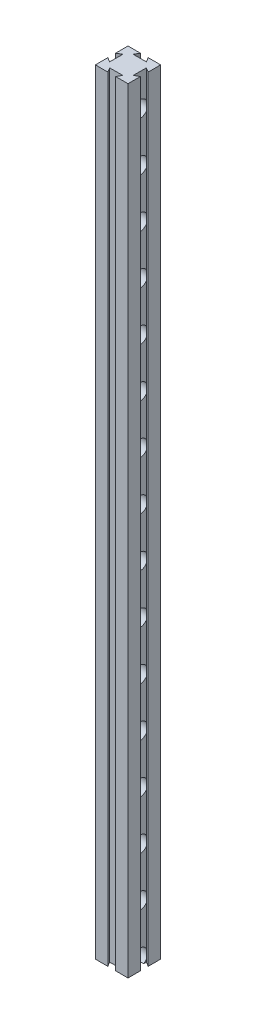
from build123d import *

# Parameters (mm, degrees)
BOSS_EXTRUDE1_DEPTH     = 1186
SKETCH3_R               = 12.5
CUT_EXTRUDE1_DEPTH      = 18
CUT_EXTRUDE1_DEPTH_BACK = 18


with BuildPart() as part:
    # Sketch1 → Boss-Extrude1 (new body)
    with BuildSketch(Plane(origin=(0, 0, 0), x_dir=(1, 0, 0), z_dir=(0, 1, 0))):
        Polygon((-25, 25), (-5.958548116, 25), (-10, 18), (10, 18), (5.958548116, 25), (25, 25), (25, 5.958548116), (18, 10), (18, -10), (25, -5.958548116), (25, -25), (5.958548116, -25), (10, -18), (-10, -18), (-5.958548116, -25), (-25, -25), (-25, -5.958548116), (-18, -10), (-18, 10), (-25, 5.958548116), align=None)
    extrude(amount=BOSS_EXTRUDE1_DEPTH)

    # Sketch3 → Cut-Extrude1 (cut, two sides)
    with BuildSketch(Plane(origin=(0, 0, 0), x_dir=(0, 0, -1), z_dir=(1, 0, 0))) as cut_extrude1_sk:
        with Locations((0, 1136)):
            Circle(SKETCH3_R)
        with Locations((0, 1061)):
            Circle(SKETCH3_R)
        with Locations((0, 986)):
            Circle(SKETCH3_R)
        with Locations((0, 911)):
            Circle(SKETCH3_R)
        with Locations((0, 836)):
            Circle(SKETCH3_R)
        with Locations((0, 761)):
            Circle(SKETCH3_R)
        with Locations((0, 686)):
            Circle(SKETCH3_R)
        with Locations((0, 611)):
            Circle(SKETCH3_R)
        with Locations((0, 536)):
            Circle(SKETCH3_R)
        with Locations((0, 461)):
            Circle(SKETCH3_R)
        with Locations((0, 386)):
            Circle(SKETCH3_R)
        with Locations((0, 311)):
            Circle(SKETCH3_R)
        with Locations((0, 236)):
            Circle(SKETCH3_R)
        with Locations((0, 161)):
            Circle(SKETCH3_R)
        with Locations((0, 86)):
            Circle(SKETCH3_R)
        with Locations((0, 11)):
            Circle(SKETCH3_R)
        with Locations((0, -64)):
            Circle(SKETCH3_R)
        with Locations((0, -139)):
            Circle(SKETCH3_R)
        with Locations((0, -214)):
            Circle(SKETCH3_R)
        with Locations((0, -289)):
            Circle(SKETCH3_R)
        with Locations((0, -364)):
            Circle(SKETCH3_R)
        with Locations((0, -439)):
            Circle(SKETCH3_R)
        with Locations((0, -514)):
            Circle(SKETCH3_R)
    extrude(amount=CUT_EXTRUDE1_DEPTH, mode=Mode.SUBTRACT)
    extrude(cut_extrude1_sk.sketch, amount=-CUT_EXTRUDE1_DEPTH_BACK, mode=Mode.SUBTRACT)


solid = part.part
